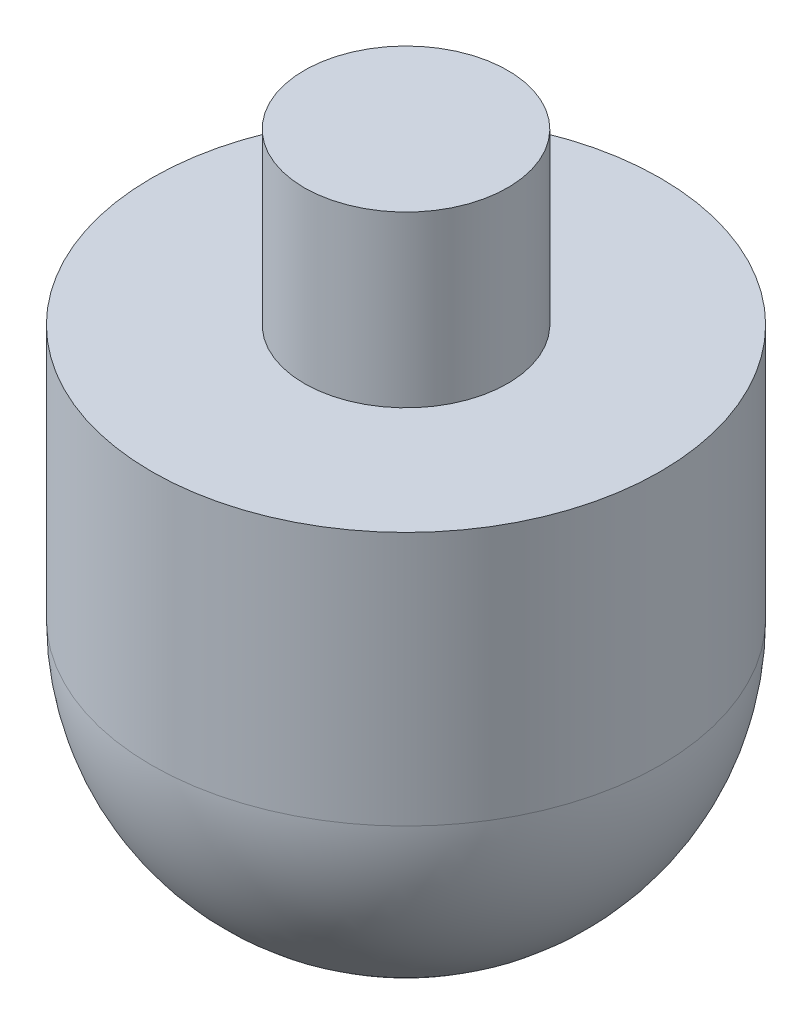
from build123d import *


with BuildPart() as part:
    # Sketch1 → Revolve1 (revolve)
    with BuildSketch(Plane.XY):
        with BuildLine():
            Line((0, 0), (-6, 0))
            Line((-6, 0), (-6, -10))
            Line((-6, -10), (-15, -10))
            Line((-15, -10), (-15, -25))
            ThreePointArc((-15, -25), (-10.606601718, -35.606601718), (0, -40))
            Line((0, -40), (0, 0))
        make_face()
    revolve(axis=Axis((0, 45.66341707, 0), (0, -1, 0)))


solid = part.part
